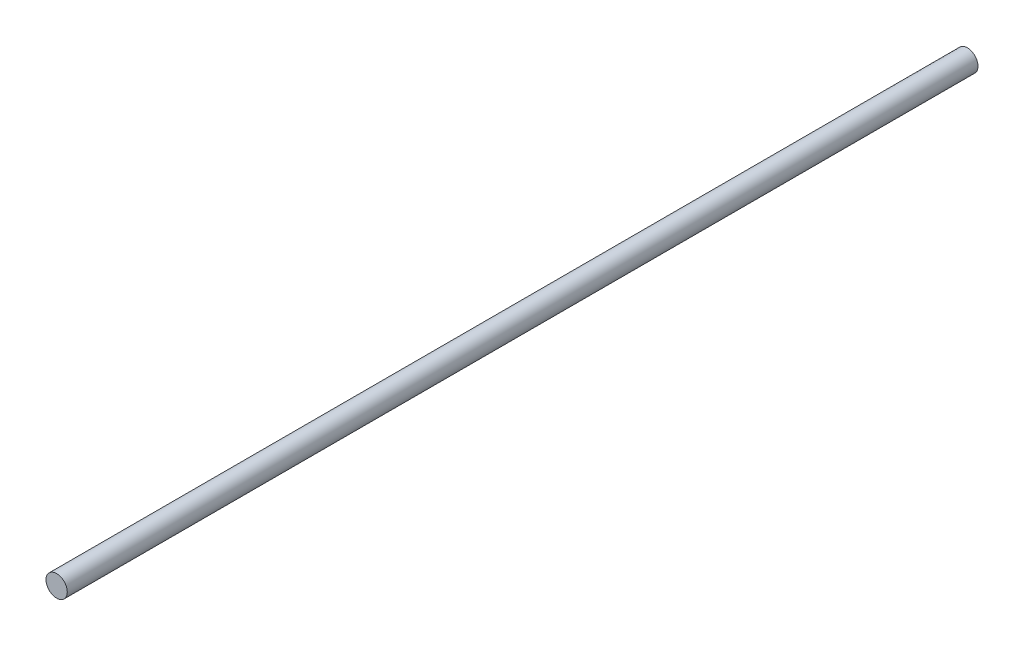
from build123d import *

# Parameters (mm, degrees)
ESBO_O1_R                = 4
RESSALTO_EXTRUS_O1_DEPTH = 171


with BuildPart() as part:
    # Esboço1 → Ressalto-extrusão1 (new, symmetric)
    with BuildSketch(Plane.XY):
        Circle(ESBO_O1_R)
    extrude(amount=RESSALTO_EXTRUS_O1_DEPTH, both=True)


solid = part.part
